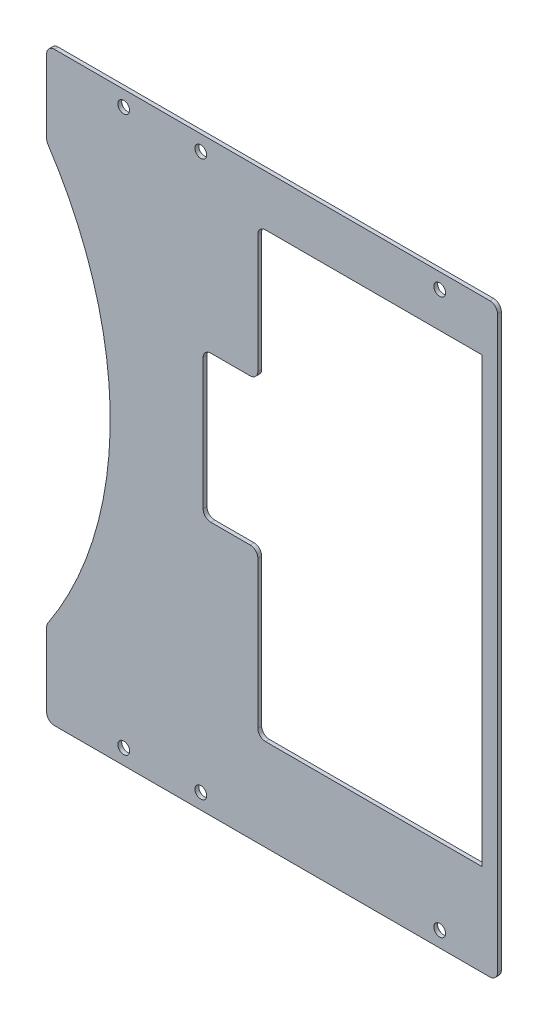
from build123d import *

# Parameters (mm, degrees)
SKETCH_1_W          = 117
SKETCH_1_H          = 152
SKETCH_1_R          = 1.525
EXTRUDE_1_DEPTH     = 1
SKETCH_2_R          = 97.5
SKETCH_2_W          = 62.201961009
SKETCH_2_H          = 115
CUT_EXTRUDE_1_DEPTH = 10
SKETCH_3_W          = 20
SKETCH_3_H          = 37.999993186
CUT_EXTRUDE_2_DEPTH = 10
FILLET_1_R          = 2
SKETCH_6_W          = 4
SKETCH_6_H          = 115
EXTRUDE_2_DEPTH     = 1


with BuildPart() as part:
    # 草图1 → 凸台-拉伸1 (new body)
    with BuildSketch(Plane.XY):
        with Locations((38.5, 0)):
            Rectangle(SKETCH_1_W, SKETCH_1_H)
        with Locations((0, 72)):
            Circle(SKETCH_1_R, mode=Mode.SUBTRACT)
        with Locations((0, -72)):
            Circle(SKETCH_1_R, mode=Mode.SUBTRACT)
        with Locations((20, 72)):
            Circle(SKETCH_1_R, mode=Mode.SUBTRACT)
        with Locations((82, 72)):
            Circle(SKETCH_1_R, mode=Mode.SUBTRACT)
        with Locations((82, -72)):
            Circle(SKETCH_1_R, mode=Mode.SUBTRACT)
        with Locations((20, -72)):
            Circle(SKETCH_1_R, mode=Mode.SUBTRACT)
    extrude(amount=EXTRUDE_1_DEPTH)

    # 草图2 → 切除-拉伸1 (cut)
    with BuildSketch(Plane(origin=(0, 0, 0), x_dir=(-1, 0, 0), z_dir=(0, 0, -1))):
        with Locations((101, 0)):
            Circle(SKETCH_2_R)
        with Locations((-65.899019495, 5.300000572)):
            Rectangle(SKETCH_2_W, SKETCH_2_H)
    extrude(amount=-CUT_EXTRUDE_1_DEPTH, mode=Mode.SUBTRACT)

    # 草图3 → 切除-拉伸2 (cut)
    with BuildSketch(Plane(origin=(0, 0, 0), x_dir=(-1, 0, 0), z_dir=(0, 0, -1))):
        with Locations((-30.6, 8.999996593)):
            Rectangle(SKETCH_3_W, SKETCH_3_H)
    extrude(amount=-CUT_EXTRUDE_2_DEPTH, mode=Mode.SUBTRACT)

    # 圆角1
    fillet_1_edges = [part.edges().sort_by_distance(p)[0] for p in [
        (-20, 54.270157545, 0.5),
        (-20, -54.270157545, 0.5),
        (34.798038991, 62.800000572, 0.5),
        (34.798038991, -52.199999428, 0.5),
        (34.798038991, -10, 0.5),
        (34.798038991, 27.999993186, 0.5),
        (20.6, 27.999993186, 0.5),
        (20.6, -10, 0.5),
        (-20, 76, 0.5),
        (97, 76, 0.5),
        (97, -76, 0.5),
        (-20, -76, 0.5),
    ]]
    fillet(fillet_1_edges, radius=FILLET_1_R)

    # 草图6 → 凸台-拉伸2 (add)
    with BuildSketch(Plane.XY.offset(1)):
        with Locations((95, 5.300000572)):
            Rectangle(SKETCH_6_W, SKETCH_6_H)
    extrude(amount=-EXTRUDE_2_DEPTH)


solid = part.part
